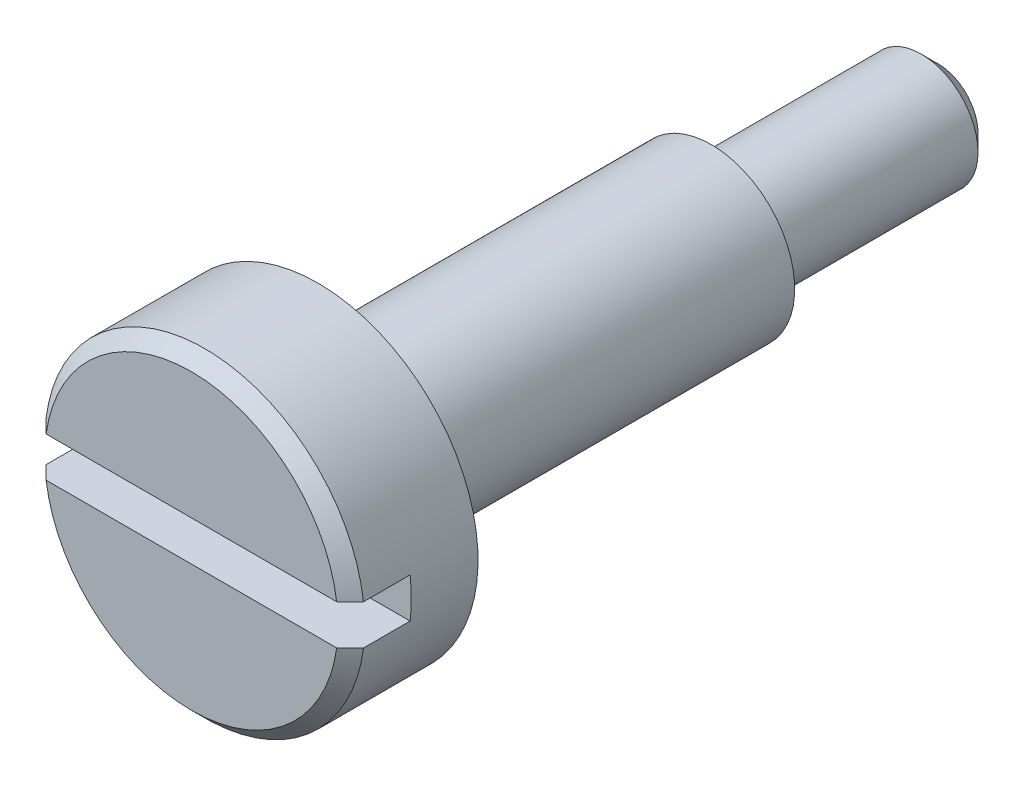
from build123d import *

# Parameters (mm, degrees)
SKETCH2_R           = 2.4
BOSS_EXTRUDE1_DEPTH = 11.2
SKETCH4_OUTSIDE_W   = 9.42
SKETCH4_OUTSIDE_H   = 9.42
SKETCH4_OUTSIDE_R   = 1.25
CUT_EXTRUDE1_DEPTH  = 9.3
SKETCH5_OUTSIDE_W   = 9.42
SKETCH5_OUTSIDE_H   = 9.42
SKETCH5_OUTSIDE_R   = 0.85
CUT_EXTRUDE2_DEPTH  = 3.4
SKETCH6_W           = 5
SKETCH6_H           = 0.6
CUT_EXTRUDE3_DEPTH  = 0.9
FILLET1_R           = 0.1
CHAMFER2_SIZE       = 0.2
CHAMFER1_SIZE       = 0.25


with BuildPart() as part:
    # Sketch2 → Boss-Extrude1 (new body)
    with BuildSketch(Plane.XY):
        Circle(SKETCH2_R)
    extrude(amount=-BOSS_EXTRUDE1_DEPTH)

    # Sketch4 outside → Cut-Extrude1 (cut)
    with BuildSketch(Plane(origin=(0, 0, -11.2), x_dir=(-1, 0, 0), z_dir=(0, 0, -1))):
        Rectangle(SKETCH4_OUTSIDE_W, SKETCH4_OUTSIDE_H)
        Circle(SKETCH4_OUTSIDE_R, mode=Mode.SUBTRACT)
    extrude(amount=-CUT_EXTRUDE1_DEPTH, mode=Mode.SUBTRACT)

    # Sketch5 outside → Cut-Extrude2 (cut)
    with BuildSketch(Plane(origin=(0, 0, -11.2), x_dir=(-1, 0, 0), z_dir=(0, 0, -1))):
        Rectangle(SKETCH5_OUTSIDE_W, SKETCH5_OUTSIDE_H)
        Circle(SKETCH5_OUTSIDE_R, mode=Mode.SUBTRACT)
    extrude(amount=-CUT_EXTRUDE2_DEPTH, mode=Mode.SUBTRACT)

    # Sketch6 → Cut-Extrude3 (cut)
    with BuildSketch(Plane.XY):
        Rectangle(SKETCH6_W, SKETCH6_H)
    extrude(amount=-CUT_EXTRUDE3_DEPTH, mode=Mode.SUBTRACT)

    # Fillet1
    fillet1_edges = [part.edges().sort_by_distance(p)[0] for p in [
        (1.25, 0, -1.9),
        (0.85, 0, -7.8),
    ]]
    fillet(fillet1_edges, radius=FILLET1_R)

    # Chamfer2
    chamfer2_edges = [part.edges().sort_by_distance(p)[0] for p in [
        (0, 2.4, 0),
        (0, -2.4, 0),
    ]]
    chamfer(chamfer2_edges, length=CHAMFER2_SIZE)

    # Chamfer1
    chamfer1_edges = [part.edges().sort_by_distance(p)[0] for p in [
        (0.85, 0, -11.2),
    ]]
    chamfer(chamfer1_edges, length=CHAMFER1_SIZE)


solid = part.part
